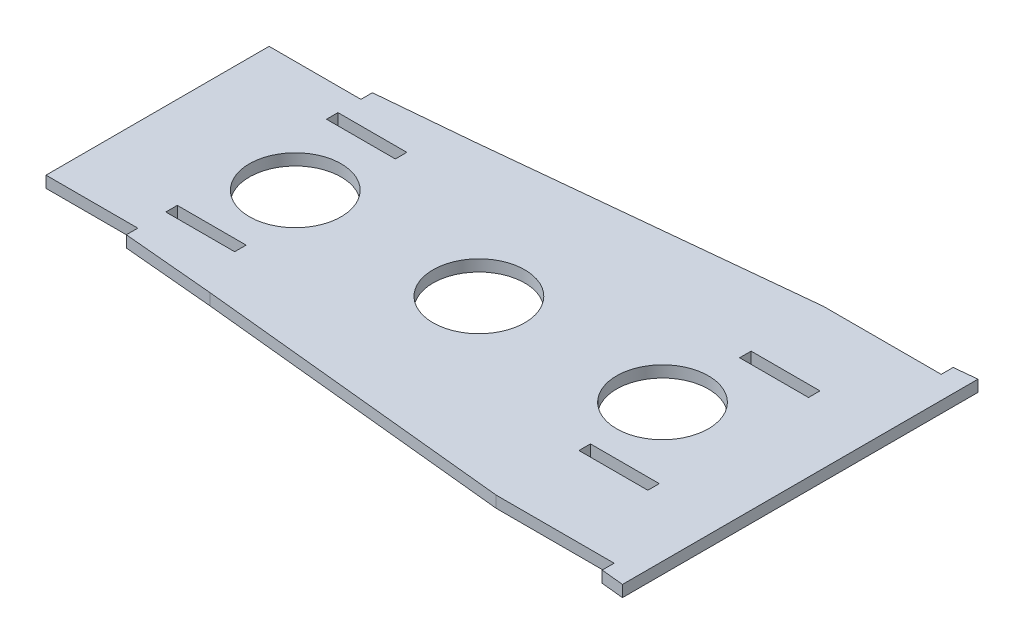
from build123d import *

# Parameters (mm, degrees)
BOSS_EXTRUDE2_DEPTH  = 3.175
SKETCH6_W            = 19.05
SKETCH6_H            = 3.175
CUT_EXTRUDE5_DEPTH   = 3.175
LPATTERN1_COUNT      = 2
LPATTERN1_PITCH      = 114.3
LPATTERN1_COUNT_DIR2 = 2
LPATTERN1_PITCH_DIR2 = 44.45
SKETCH7_R            = 12.7
CUT_EXTRUDE6_DEPTH   = 3.175
LPATTERN2_COUNT      = 2
LPATTERN2_PITCH      = 50.8
LPATTERN2_COL_COUNT  = 2
LPATTERN2_COL_PITCH  = 50.8


with BuildPart() as part:
    # Sketch1 → Boss-Extrude2 (new body)
    with BuildSketch(Plane(origin=(0, 0, 0), x_dir=(1, 0, 0), z_dir=(0, 1, 0))):
        Polygon((24.645444356, 45.246601981), (-63.5, 36.321593844), (-88.9, 34.035796922), (-88.9, 30.860796922), (-114.3, 30.860796922), (-114.3, -30.860796922), (-88.9, -30.860796922), (-88.9, -34.035796922), (-63.5, -36.321593844), (24.645444356, -45.246601981), (57.256759974, -45.246601981), (57.256759974, -48.548601981), (63.5, -49.18075), (63.5, 49.18075), (57.256759974, 48.548601981), (57.256759974, 45.246601981), align=None)
    extrude(amount=BOSS_EXTRUDE2_DEPTH)

    # Sketch6 → Cut-Extrude5 (cut)
    with BuildSketch(Plane(origin=(0, 3.175, 0), x_dir=(1, 0, 0), z_dir=(0, 1, 0))):
        with Locations((-79.375, 22.923296922)):
            Rectangle(SKETCH6_W, SKETCH6_H)
    cut_extrude5 = extrude(amount=-CUT_EXTRUDE5_DEPTH, mode=Mode.SUBTRACT)

    # LPattern1: Cut-Extrude5 2 × 2
    with Locations(*[(i * LPATTERN1_PITCH, 0, j * LPATTERN1_PITCH_DIR2) for i in range(LPATTERN1_COUNT) for j in range(LPATTERN1_COUNT_DIR2) if (i, j) != (0, 0)]):
        add(cut_extrude5, mode=Mode.SUBTRACT)

    # Sketch7 → Cut-Extrude6 (cut)
    with BuildSketch(Plane(origin=(0, 3.175, 0), x_dir=(1, 0, 0), z_dir=(0, 1, 0))):
        with Locations((-25.4, 0)):
            Circle(SKETCH7_R)
    cut_extrude6 = extrude(amount=-CUT_EXTRUDE6_DEPTH, mode=Mode.SUBTRACT)

    # LPattern2: Cut-Extrude6 ×2
    with Locations(*[(-i * LPATTERN2_PITCH, 0, 0) for i in range(1, LPATTERN2_COUNT)]):
        add(cut_extrude6, mode=Mode.SUBTRACT)

    # LPattern2 col: Cut-Extrude6 ×2
    with Locations(*[(i * LPATTERN2_COL_PITCH, 0, 0) for i in range(1, LPATTERN2_COL_COUNT)]):
        add(cut_extrude6, mode=Mode.SUBTRACT)


solid = part.part
